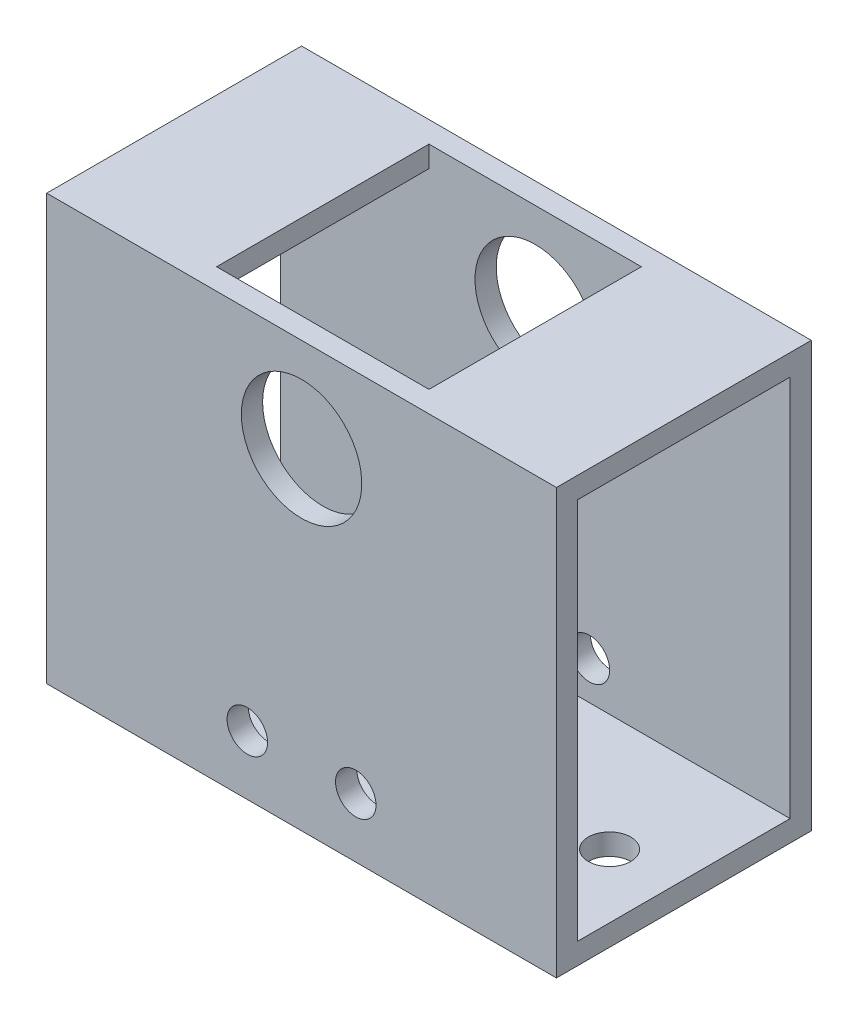
from build123d import *

# Parameters (mm, degrees)
SKETCH1_W           = 38.1
SKETCH1_H           = 63.5
SKETCH1_W_2         = 31.75
SKETCH1_H_2         = 57.15
BOSS_EXTRUDE1_DEPTH = 76.2
SKETCH2_R           = 9
SKETCH2_R_2         = 3.025
CUT_EXTRUDE1_DEPTH  = 38.1
SKETCH3_W           = 31.75
SKETCH3_H           = 31.75
CUT_EXTRUDE2_DEPTH  = 76.2
SKETCH4_R           = 3.175
CUT_EXTRUDE3_DEPTH  = 32.75


with BuildPart() as part:
    # Sketch1 → Boss-Extrude1 (new body)
    with BuildSketch(Plane(origin=(0, 0, 0), x_dir=(0, 0, -1), z_dir=(1, 0, 0))):
        Rectangle(SKETCH1_W, SKETCH1_H)
        Rectangle(SKETCH1_W_2, SKETCH1_H_2, mode=Mode.SUBTRACT)
    extrude(amount=BOSS_EXTRUDE1_DEPTH)

    # Sketch2 → Cut-Extrude1 (cut, symmetric)
    with BuildSketch(Plane.XY):
        with Locations((38.1, 17.7)):
            Circle(SKETCH2_R)
        with Locations((46.205, -22.86)):
            Circle(SKETCH2_R_2)
        with Locations((29.995, -22.86)):
            Circle(SKETCH2_R_2)
    extrude(amount=CUT_EXTRUDE1_DEPTH, both=True, mode=Mode.SUBTRACT)

    # Sketch3 → Cut-Extrude2 (cut)
    with BuildSketch(Plane(origin=(0, 0, 0), x_dir=(1, 0, 0), z_dir=(0, 1, 0))):
        with Locations((38.1, 0)):
            Rectangle(SKETCH3_W, SKETCH3_H)
    extrude(amount=CUT_EXTRUDE2_DEPTH, mode=Mode.SUBTRACT)

    # Sketch4 → Cut-Extrude3 (cut, through all)
    with BuildSketch(Plane(origin=(0, 0, 0), x_dir=(1, 0, 0), z_dir=(0, 1, 0))):
        with Locations((9.525, -1.5875)):
            Circle(SKETCH4_R)
        with Locations((66.675, -1.5875)):
            Circle(SKETCH4_R)
    extrude(amount=-CUT_EXTRUDE3_DEPTH, mode=Mode.SUBTRACT)


solid = part.part
